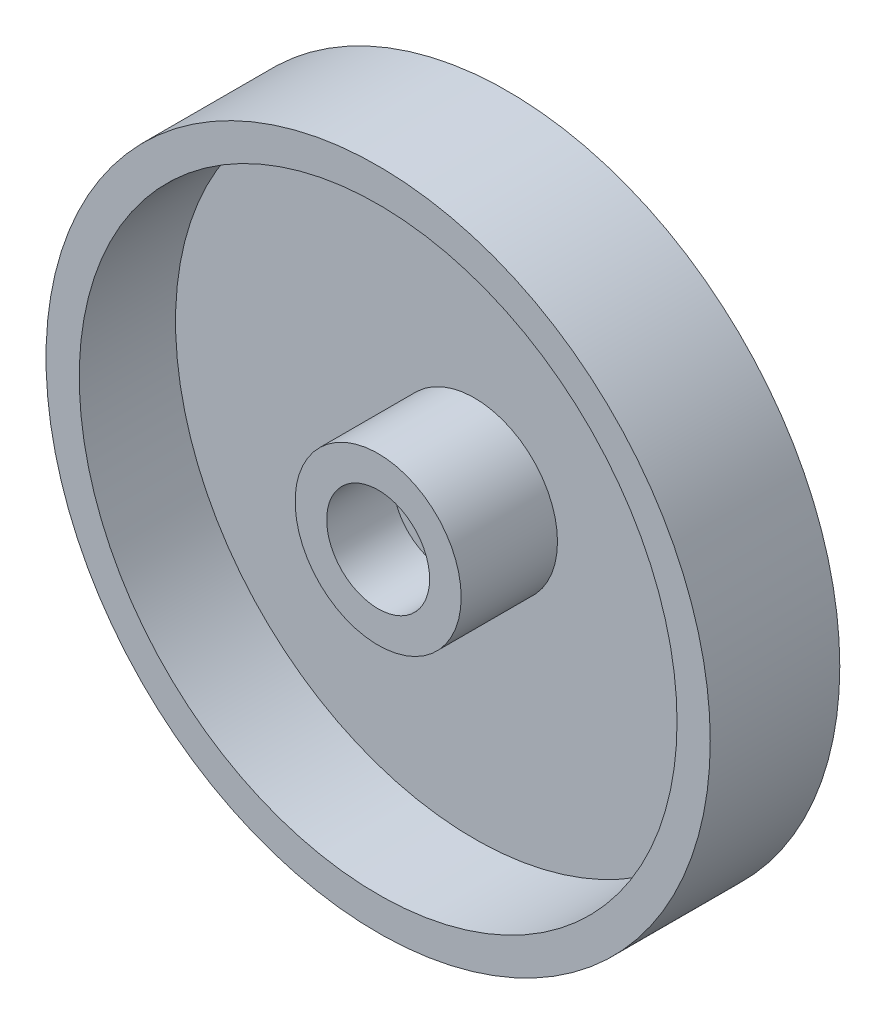
from build123d import *

# Parameters (mm, degrees)
SKETCH_1_R          = 5
SKETCH_1_R_2        = 3.1
EXTRUDE_1_DEPTH     = 4
SKETCH_1_3_R        = 20
SKETCH_1_3_R_2      = 18
EXTRUDE_2_DEPTH     = 4
SKETCH_1_4_R        = 20
EXTRUDE_3_DEPTH     = 2
SKETCH_2_R          = 20
EXTRUDE_4_DEPTH     = 1.8
CUT_EXTRUDE_START   = -1.8
SKETCH_4_R          = 18
SKETCH_4_R_2        = 5
CUT_EXTRUDE_1_DEPTH = 1.8


with BuildPart() as part:
    # 草图1 → 凸台-拉伸1 (new body)
    with BuildSketch(Plane.XY):
        Circle(SKETCH_1_R)
        Circle(SKETCH_1_R_2, mode=Mode.SUBTRACT)
    extrude(amount=EXTRUDE_1_DEPTH)



with BuildPart() as body_2:
    # 草图1<3> → 凸台-拉伸2 (new body)
    with BuildSketch(Plane.XY):
        Circle(SKETCH_1_3_R)
        Circle(SKETCH_1_3_R_2, mode=Mode.SUBTRACT)
    extrude(amount=EXTRUDE_2_DEPTH)


with BuildPart() as part_1:
    add(part.part)

    add(body_2.part)  # 凸台-拉伸3 merges body 2
    # 草图1<4> → 凸台-拉伸3 (add)
    with BuildSketch(Plane.XY):
        Circle(SKETCH_1_4_R)
    extrude(amount=-EXTRUDE_3_DEPTH)

    # 草图2 → 凸台-拉伸4 (add)
    with BuildSketch(Plane(origin=(0, 0, -2), x_dir=(-1, 0, 0), z_dir=(0, 0, -1))):
        Circle(SKETCH_2_R)
    extrude(amount=EXTRUDE_4_DEPTH)

    # 草图4 → 切除-拉伸1 (cut)
    with BuildSketch(Plane.XY.offset(CUT_EXTRUDE_START)):
        Circle(SKETCH_4_R)
        Circle(SKETCH_4_R_2, mode=Mode.SUBTRACT)
    extrude(amount=CUT_EXTRUDE_1_DEPTH, mode=Mode.SUBTRACT)


solid = part_1.part
